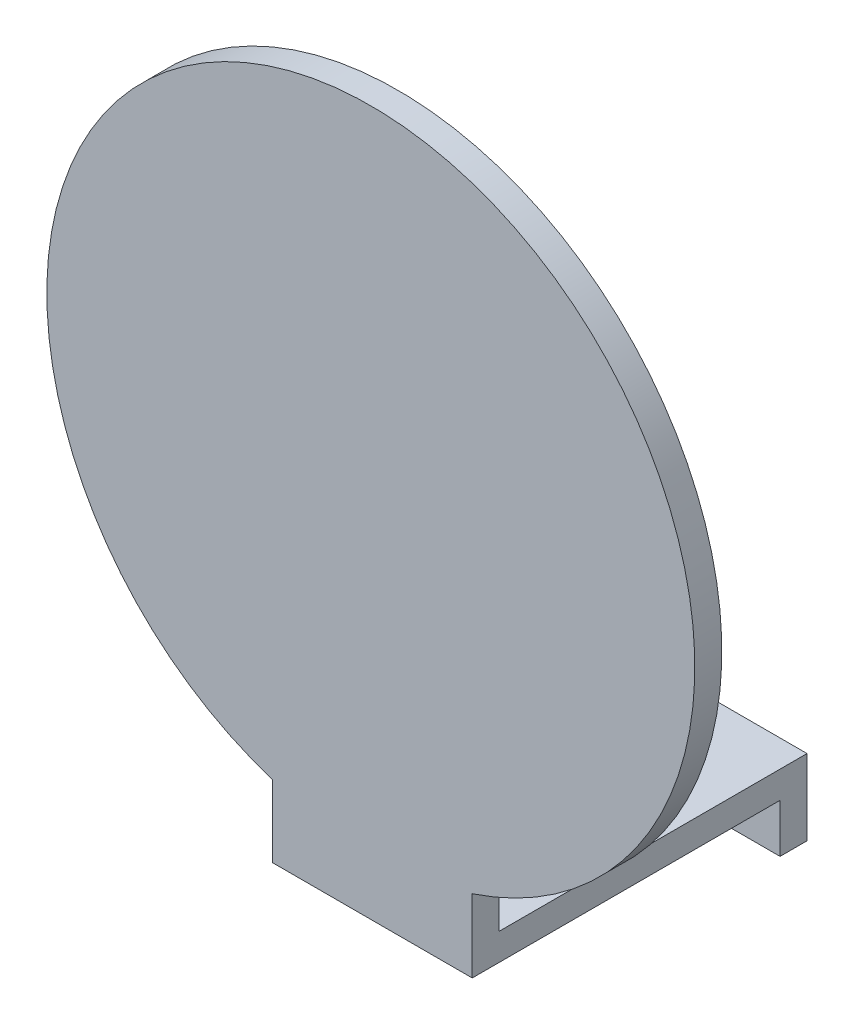
from build123d import *

# Parameters (mm, degrees)
SKETCH2_W           = 37
SKETCH2_H           = 8
SKETCH2_R           = 2.1
BOSS_EXTRUDE1_DEPTH = 5
SKETCH3_W           = 37
SKETCH3_H           = 5
BOSS_EXTRUDE2_DEPTH = 6
SKETCH4_W           = 37
SKETCH4_H           = 5
BOSS_EXTRUDE3_DEPTH = 57
SKETCH5_W           = 37
SKETCH5_H           = 5
BOSS_EXTRUDE4_DEPTH = 27.5
SKETCH6_R           = 60
BOSS_EXTRUDE5_DEPTH = 5


with BuildPart() as part:
    # Sketch2 → Boss-Extrude1 (new body)
    with BuildSketch(Plane.XY.offset(-2347.018325578)):
        with Locations((0, 1)):
            Rectangle(SKETCH2_W, SKETCH2_H)
        with Locations((10, 1)):
            Circle(SKETCH2_R, mode=Mode.SUBTRACT)
        with Locations((-10, 1)):
            Circle(SKETCH2_R, mode=Mode.SUBTRACT)
    extrude(amount=BOSS_EXTRUDE1_DEPTH)

    # Sketch3 → Boss-Extrude2 (add)
    with BuildSketch(Plane(origin=(0, 5, 0), x_dir=(1, 0, 0), z_dir=(0, 1, 0))):
        with Locations((0, 2344.518325578)):
            Rectangle(SKETCH3_W, SKETCH3_H)
    extrude(amount=BOSS_EXTRUDE2_DEPTH)

    # Sketch4 → Boss-Extrude3 (add)
    with BuildSketch(Plane.XY.offset(-2342.018325578)):
        with Locations((0, 8.5)):
            Rectangle(SKETCH4_W, SKETCH4_H)
    extrude(amount=BOSS_EXTRUDE3_DEPTH)

    # Sketch5 → Boss-Extrude4 (add)
    with BuildSketch(Plane(origin=(0, 11, 0), x_dir=(1, 0, 0), z_dir=(0, 1, 0))):
        with Locations((0, 2287.518325578)):
            Rectangle(SKETCH5_W, SKETCH5_H)
    extrude(amount=BOSS_EXTRUDE4_DEPTH)

    # Sketch6 → Boss-Extrude5 (add)
    with BuildSketch(Plane.XY.offset(-2285.018325578)):
        with Locations((-0.279431791, 76.5)):
            Circle(SKETCH6_R)
    extrude(amount=-BOSS_EXTRUDE5_DEPTH)


solid = part.part
